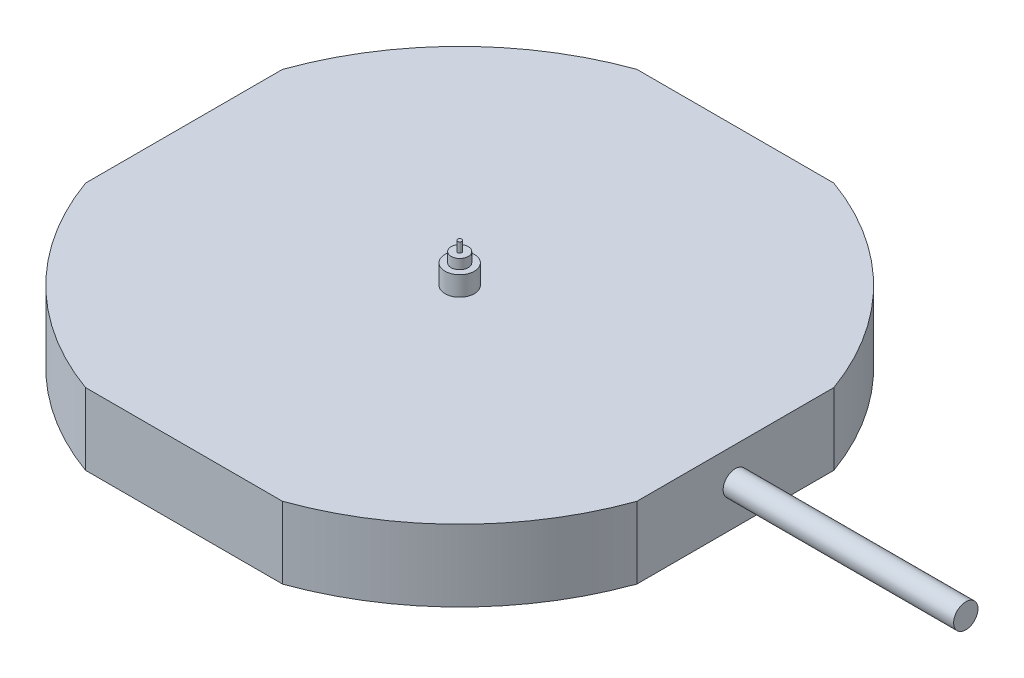
from build123d import *

# Parameters (mm, degrees)
SKETCH1_R           = 12
BOSS_EXTRUDE1_DEPTH = 2.94
CUT_EXTRUDE1_DEPTH  = 2.94
CUT_EXTRUDE2_DEPTH  = 2.94
SKETCH7_R           = 0.5
BOSS_EXTRUDE4_DEPTH = 9.45
SKETCH8_R           = 0.6
BOSS_EXTRUDE5_DEPTH = 0.8
SKETCH9_R           = 0.35
BOSS_EXTRUDE6_DEPTH = 0.4
SKETCH10_R          = 0.085
BOSS_EXTRUDE7_DEPTH = 0.4


with BuildPart() as part:
    # Sketch1 → Boss-Extrude1 (new body)
    with BuildSketch(Plane(origin=(0, 0, 0), x_dir=(1, 0, 0), z_dir=(0, 1, 0))):
        Circle(SKETCH1_R)
    extrude(amount=BOSS_EXTRUDE1_DEPTH)

    # Sketch2 → Cut-Extrude1 (cut)
    with BuildSketch(Plane(origin=(0, 0, 0), x_dir=(1, 0, 0), z_dir=(0, 1, 0))):
        Polygon((-11.3, 0), (-11.3, 4.756450674), (-12.628390715, 4.756450674), (-12.628390715, -4.839844075), (-11.3, -4.839844075), align=None)
        Polygon((12.628390715, -4.839844075), (12.628390715, 4.756450674), (11.3, 4.756450674), (11.3, 0), (11.3, -4.839844075), align=None)
    extrude(amount=CUT_EXTRUDE1_DEPTH, mode=Mode.SUBTRACT)

    # Sketch3 → Cut-Extrude2 (cut)
    with BuildSketch(Plane(origin=(0, 0, 0), x_dir=(1, 0, 0), z_dir=(0, 1, 0))):
        Polygon((0, -11.3), (4.998184115, -11.3), (4.998184115, -12.991968643), (-5.196787457, -12.991968643), (-5.196787457, -11.3), align=None)
        Polygon((-5.196787457, 12.991968643), (4.998184115, 12.991968643), (4.998184115, 11.3), (0, 11.3), (-5.196787457, 11.3), align=None)
    extrude(amount=CUT_EXTRUDE2_DEPTH, mode=Mode.SUBTRACT)

    # Sketch7 → Boss-Extrude4 (add)
    with BuildSketch(Plane(origin=(11.3, 0, 0), x_dir=(0, 0, -1), z_dir=(1, 0, 0))):
        with Locations((0, 1.58)):
            Circle(SKETCH7_R)
    extrude(amount=BOSS_EXTRUDE4_DEPTH)

    # Sketch8 → Boss-Extrude5 (add)
    with BuildSketch(Plane(origin=(0, 2.94, 0), x_dir=(1, 0, 0), z_dir=(0, 1, 0))):
        Circle(SKETCH8_R)
    extrude(amount=BOSS_EXTRUDE5_DEPTH)

    # Sketch9 → Boss-Extrude6 (add)
    with BuildSketch(Plane(origin=(0, 3.74, 0), x_dir=(1, 0, 0), z_dir=(0, 1, 0))):
        Circle(SKETCH9_R)
    extrude(amount=BOSS_EXTRUDE6_DEPTH)

    # Sketch10 → Boss-Extrude7 (add)
    with BuildSketch(Plane(origin=(0, 4.14, 0), x_dir=(1, 0, 0), z_dir=(0, 1, 0))):
        Circle(SKETCH10_R)
    extrude(amount=BOSS_EXTRUDE7_DEPTH)


solid = part.part
